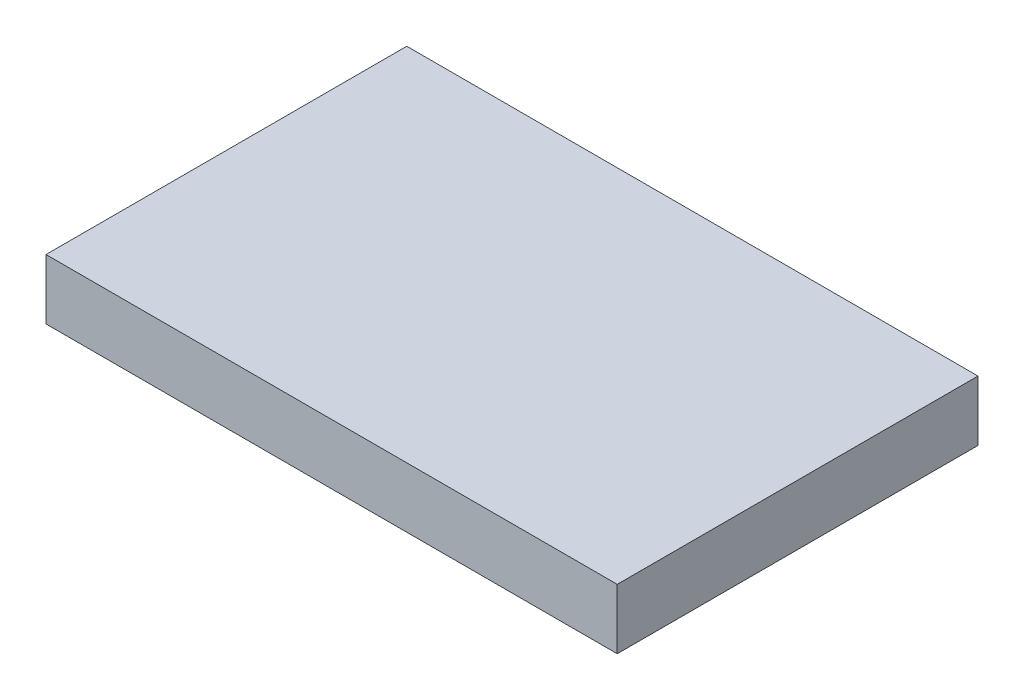
from build123d import *

# Parameters (mm, degrees)
SKETCH1_W           = 38
SKETCH1_H           = 24
BOSS_EXTRUDE1_DEPTH = 4


with BuildPart() as part:
    # Sketch1 → Boss-Extrude1 (new body)
    with BuildSketch(Plane(origin=(0, 0, 0), x_dir=(1, 0, 0), z_dir=(0, 1, 0))):
        with Locations((19, -12)):
            Rectangle(SKETCH1_W, SKETCH1_H)
    extrude(amount=BOSS_EXTRUDE1_DEPTH)


solid = part.part
